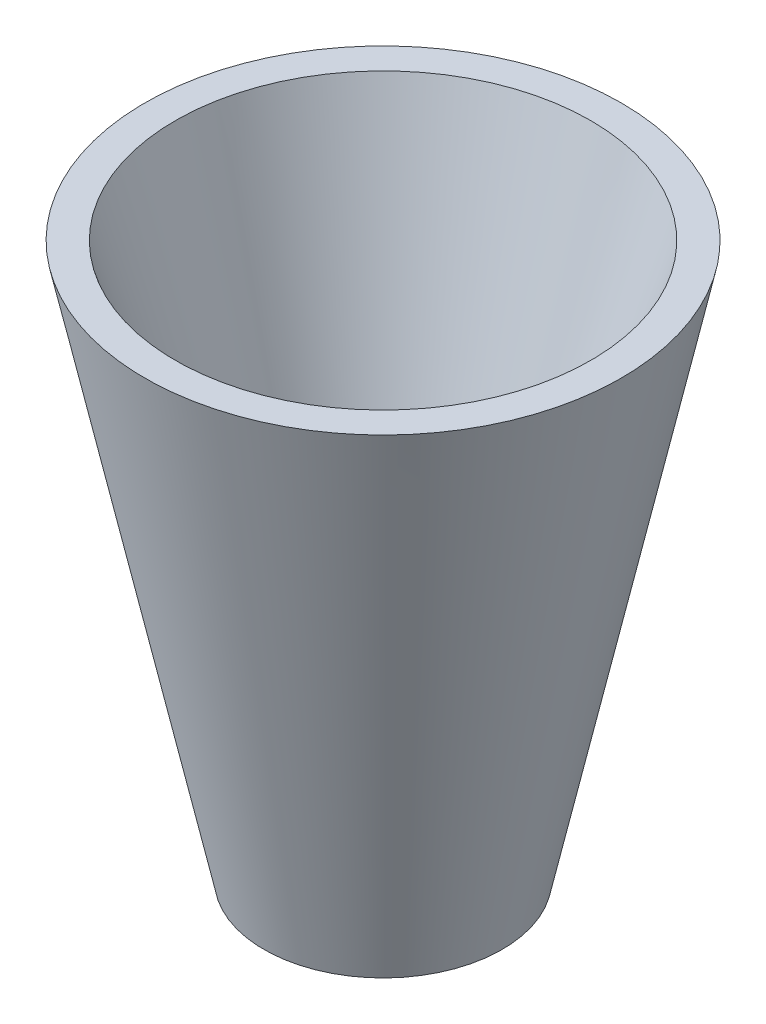
from build123d import *


with BuildPart() as part:
    # Sketch3 → Revolve1 (revolve)
    with BuildSketch(Plane.XY):
        with BuildLine():
            Line((0, 0), (12.7, 0))
            Line((12.7, 0), (25.4, 59.10038719))
            Line((25.4, 59.10038719), (22.140333333, 59.10038719))
            Line((22.140333333, 59.10038719), (9.228066554, 16.982885))
            ThreePointArc((9.228066554, 16.982885), (5.738226469, 12.050952327), (0, 10.16))
            Line((0, 10.16), (0, 0))
        make_face()
    revolve(axis=Axis((0, 0, 0), (0, 1, 0)))


solid = part.part
